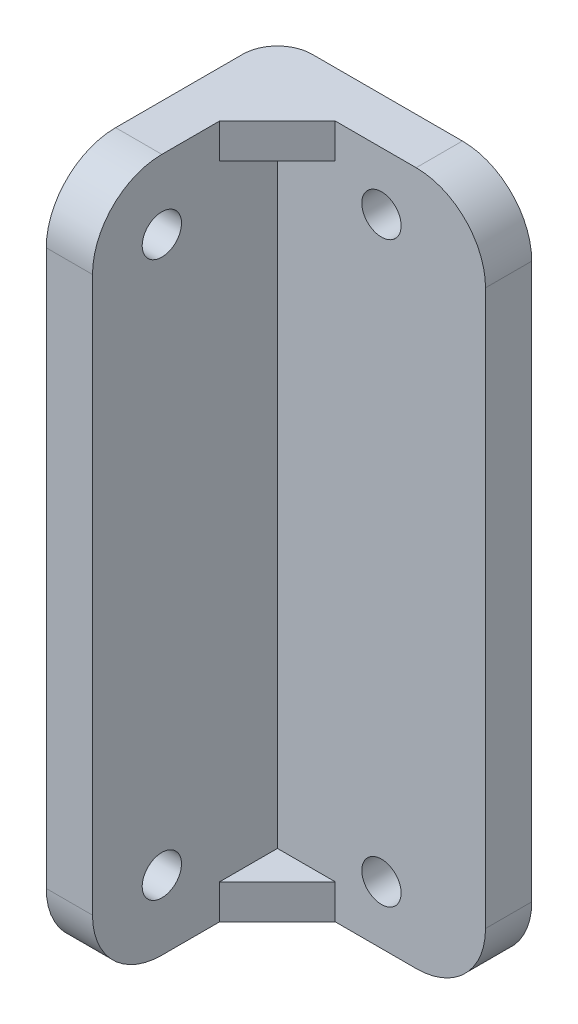
from build123d import *

# Parameters (mm, degrees)
SKETCH1_W           = 18
SKETCH1_H           = 60
SKETCH1_R           = 1.7
BOSS_EXTRUDE1_DEPTH = 4
SKETCH2_R           = 1.7
BOSS_EXTRUDE2_DEPTH = 4
FILLET1_R           = 6
BOSS_EXTRUDE3_DEPTH = 3
FILLET2_R           = 3


with BuildPart() as part:
    # Sketch1 → Boss-Extrude1 (new body)
    with BuildSketch(Plane.XY):
        with Locations((0, 25)):
            Rectangle(SKETCH1_W, SKETCH1_H)
        Circle(SKETCH1_R, mode=Mode.SUBTRACT)
        with Locations((0, 50)):
            Circle(SKETCH1_R, mode=Mode.SUBTRACT)
    extrude(amount=BOSS_EXTRUDE1_DEPTH)

    # Sketch2 → Boss-Extrude2 (add)
    with BuildSketch(Plane.ZY.offset(9)):
        with BuildLine():
            Line((0, 55), (14, 55))
            ThreePointArc((14, 55), (18.242640687, 53.242640687), (20, 49))
            Line((20, 49), (20, 1))
            ThreePointArc((20, 1), (18.242640687, -3.242640687), (14, -5))
            Line((14, -5), (0, -5))
            Line((0, -5), (0, 55))
        make_face()
        with Locations((14, 49)):
            Circle(SKETCH2_R, mode=Mode.SUBTRACT)
        with Locations((14, 1)):
            Circle(SKETCH2_R, mode=Mode.SUBTRACT)
    extrude(amount=BOSS_EXTRUDE2_DEPTH)

    # Fillet1
    fillet1_edges = [part.edges().sort_by_distance(p)[0] for p in [
        (9, 55, 2),
        (9, -5, 2),
    ]]
    fillet(fillet1_edges, radius=FILLET1_R)

    # Sketch3 → Boss-Extrude3 (add)
    with BuildSketch(Plane(origin=(0, 55, 0), x_dir=(1, 0, 0), z_dir=(0, 1, 0))):
        Polygon((-4, -4), (-9, -9), (-9, -4), align=None)
    boss_extrude3 = extrude(amount=-BOSS_EXTRUDE3_DEPTH)

    # Mirror1: Boss-Extrude3 across plane
    add(boss_extrude3.mirror(Plane.ZX.offset(25)))

    # Fillet2
    fillet2_edges = [part.edges().sort_by_distance(p)[0] for p in [
        (-13, 25, 0),
    ]]
    fillet(fillet2_edges, radius=FILLET2_R)


solid = part.part
